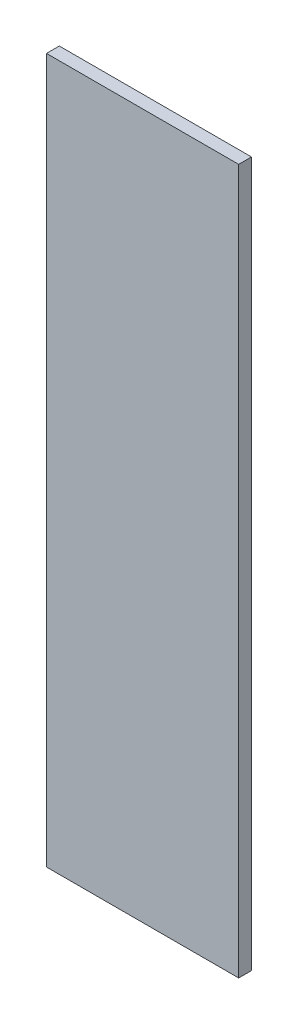
from build123d import *

# Parameters (mm, degrees)
SKIZZE1_W                       = 30
SKIZZE1_H                       = 110
AUFSATZ_LINEAR_AUSTRAGEN1_DEPTH = 2


with BuildPart() as part:
    # Skizze1 → Aufsatz-Linear austragen1 (new body)
    with BuildSketch(Plane.XY):
        with Locations((3.764478764, -37.567567568)):
            Rectangle(SKIZZE1_W, SKIZZE1_H)
    extrude(amount=AUFSATZ_LINEAR_AUSTRAGEN1_DEPTH)


solid = part.part
